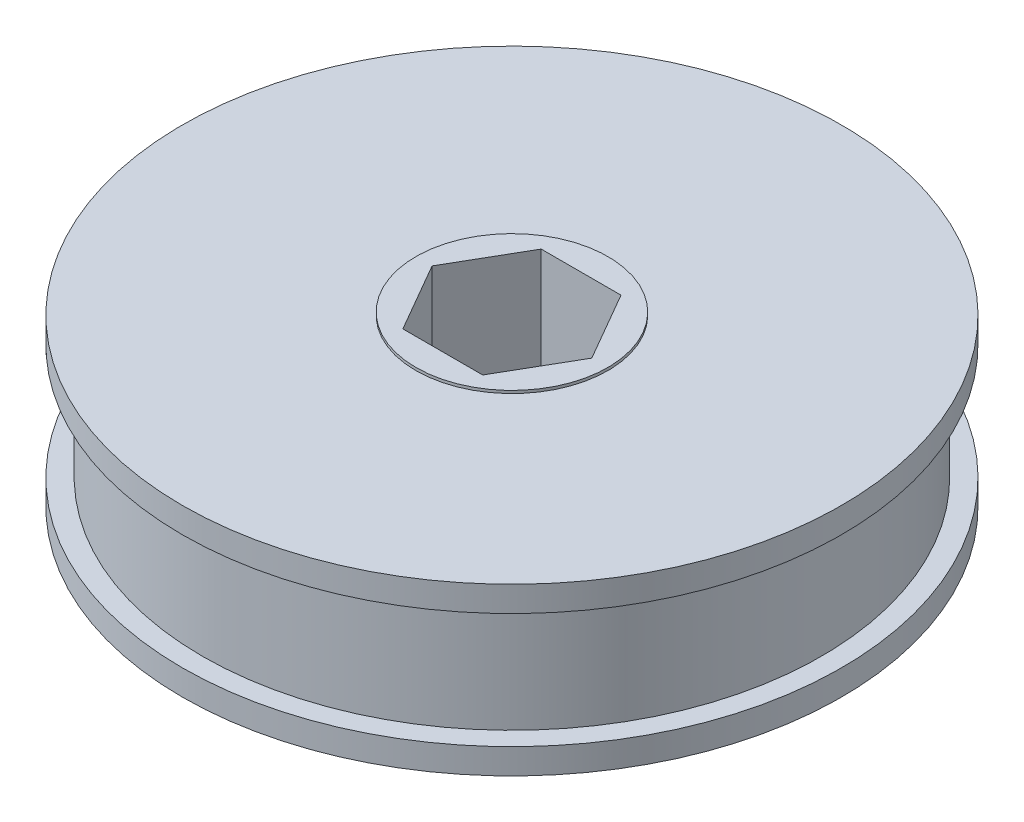
from build123d import *

# Parameters (mm, degrees)
CUT_EXTRUDE1_DEPTH      = 1
CUT_EXTRUDE1_DEPTH_BACK = 16.875


with BuildPart() as part:
    # Sketch2 → Revolve1 (revolve)
    with BuildSketch(Plane(origin=(0, 0, 0), x_dir=(0, 0, -1), z_dir=(1, 0, 0))):
        Polygon((2.54, -3.2131), (8.89, -3.2131), (8.89, -3.4671), (30.5054, -3.4671), (30.5054, -5.8166), (28.6512, -5.8166), (28.6512, -16.4846), (30.5054, -16.4846), (30.5054, -18.8341), (8.89, -18.8341), (8.89, -19.0881), (2.54, -19.0881), align=None)
    revolve(axis=Axis((0, 55, 0), (0, -1, 0)))

    # Sketch3 → Cut-Extrude1 (cut, two sides)
    with BuildSketch(Plane(origin=(0, -3.2131, 0), x_dir=(1, 0, 0), z_dir=(0, 1, 0))) as cut_extrude1_sk:
        Polygon((3.695503603, 6.4008), (-3.695503603, 6.4008), (-7.391007206, 0), (-3.695503603, -6.4008), (3.695503603, -6.4008), (7.391007206, 0), align=None)
    extrude(amount=CUT_EXTRUDE1_DEPTH, mode=Mode.SUBTRACT)
    extrude(cut_extrude1_sk.sketch, amount=-CUT_EXTRUDE1_DEPTH_BACK, mode=Mode.SUBTRACT)


solid = part.part
